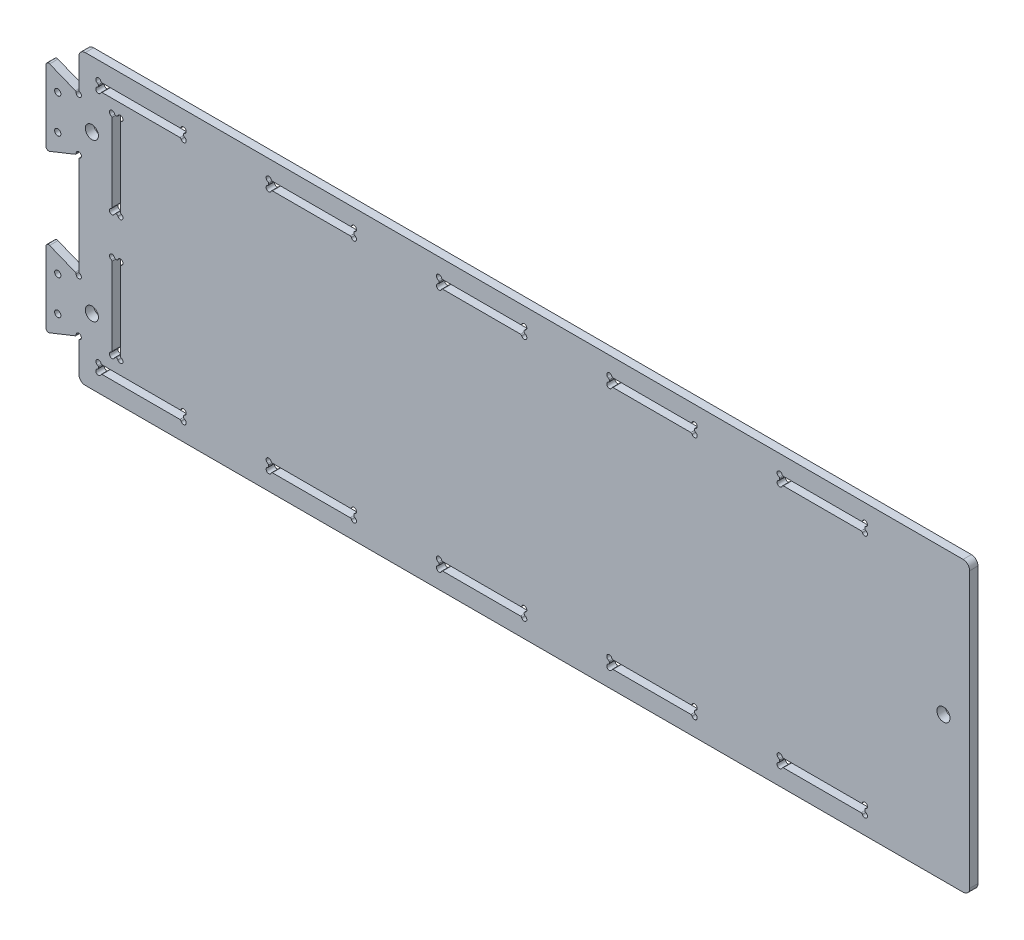
from build123d import *

# Parameters (mm, degrees)
SKETCH1_W            = 680
SKETCH1_H            = 220
BOSS_EXTRUDE1_DEPTH  = 3.175
SKETCH2_W            = 65
SKETCH2_H            = 6.35
CUT_EXTRUDE1_DEPTH   = 7.35
SKETCH3_R            = 2
CUT_EXTRUDE2_DEPTH   = 7.35
CUT_EXTRUDE3_DEPTH   = 7.35
LPATTERN1_COUNT      = 5
LPATTERN1_PITCH      = 130
MIRROR1_COPY_1_DEPTH = 7.35
MIRROR1_COPY_2_DEPTH = 7.35
MIRROR1_COPY_3_DEPTH = 7.35
MIRROR1_COPY_4_DEPTH = 7.35
SKETCH5_W            = 6.35
SKETCH5_H            = 65
CUT_EXTRUDE4_DEPTH   = 7.35
SKETCH6_R            = 2
CUT_EXTRUDE5_DEPTH   = 7.35
FILLET1_R            = 1
BOSS_EXTRUDE2_DEPTH  = 6.35
SKETCH8_R            = 2
CUT_EXTRUDE6_DEPTH   = 7.35
SKETCH10_R           = 5
CUT_EXTRUDE9_DEPTH   = 7.35
FILLET2_R            = 1
FILLET3_R            = 2
FILLET4_R            = 5
SKETCH9_R            = 2.38
CUT_EXTRUDE8_DEPTH   = 6.35


with BuildPart() as part:
    # Sketch1 → Boss-Extrude1 (new body, symmetric)
    with BuildSketch(Plane.XY):
        with Locations((340, 110)):
            Rectangle(SKETCH1_W, SKETCH1_H)
    extrude(amount=BOSS_EXTRUDE1_DEPTH, both=True)

    # Sketch2 → Cut-Extrude1 (cut, through all)
    with BuildSketch(Plane.XY.offset(3.175)):
        with Locations((567.5, 203.175)):
            Rectangle(SKETCH2_W, SKETCH2_H)
    extrude(amount=-CUT_EXTRUDE1_DEPTH, mode=Mode.SUBTRACT)

    # Sketch3 → Cut-Extrude2 (cut, through all)
    with BuildSketch(Plane.XY.offset(3.175)):
        with Locations((535, 206.35)):
            Circle(SKETCH3_R)
        with Locations((535, 200)):
            Circle(SKETCH3_R)
        with Locations((600, 200)):
            Circle(SKETCH3_R)
        with Locations((600, 206.35)):
            Circle(SKETCH3_R)
    extrude(amount=-CUT_EXTRUDE2_DEPTH, mode=Mode.SUBTRACT)

    # Sketch4 → Cut-Extrude3 (cut, through all)
    with BuildSketch(Plane.XY.offset(3.175)):
        with BuildLine():
            Line((537.828427125, 200), (597.171572875, 200))
            ThreePointArc((597.171572875, 200), (597.748923144, 199.816496581), (598.114381917, 199.333333333))
            ThreePointArc((598.114381917, 199.333333333), (601.414213562, 198.585786438), (600.666666667, 201.885618083))
            ThreePointArc((600.666666667, 201.885618083), (600.183503419, 202.251076856), (600, 202.828427125))
            Line((600, 202.828427125), (600, 203.521572875))
            ThreePointArc((600, 203.521572875), (600.183503419, 204.098923144), (600.666666667, 204.464381917))
            ThreePointArc((600.666666667, 204.464381917), (601.414213562, 207.764213562), (598.114381917, 207.016666667))
            ThreePointArc((598.114381917, 207.016666667), (597.748923144, 206.533503419), (597.171572875, 206.35))
            Line((597.171572875, 206.35), (537.828427125, 206.35))
            ThreePointArc((537.828427125, 206.35), (537.251076856, 206.533503419), (536.885618083, 207.016666667))
            ThreePointArc((536.885618083, 207.016666667), (533.585786438, 207.764213562), (534.333333333, 204.464381917))
            ThreePointArc((534.333333333, 204.464381917), (534.816496581, 204.098923144), (535, 203.521572875))
            Line((535, 203.521572875), (535, 202.828427125))
            ThreePointArc((535, 202.828427125), (534.816496581, 202.251076856), (534.333333333, 201.885618083))
            ThreePointArc((534.333333333, 201.885618083), (533.585786438, 198.585786438), (536.885618083, 199.333333333))
            ThreePointArc((536.885618083, 199.333333333), (537.251076856, 199.816496581), (537.828427125, 200))
        make_face()
    cut_extrude3 = extrude(amount=-CUT_EXTRUDE3_DEPTH, mode=Mode.SUBTRACT)

    # LPattern1: Cut-Extrude3 ×5
    with Locations(*[(-i * LPATTERN1_PITCH, 0, 0) for i in range(1, LPATTERN1_COUNT)]):
        add(cut_extrude3, mode=Mode.SUBTRACT)

    # Mirror1: Cut-Extrude3 across plane
    add(cut_extrude3.mirror(Plane.ZX.offset(110)), mode=Mode.SUBTRACT)

    # Mirror1 copy 1 sketch → Mirror1 copy 1 (cut, through all)
    with BuildSketch(Plane(origin=(-130, 220, 3.175), x_dir=(1, 0, 0), z_dir=(0, 0, 1))):
        with BuildLine():
            Line((537.828427125, -200), (597.171572875, -200))
            ThreePointArc((597.171572875, -200), (597.748923144, -199.816496581), (598.114381917, -199.333333333))
            ThreePointArc((598.114381917, -199.333333333), (601.414213562, -198.585786438), (600.666666667, -201.885618083))
            ThreePointArc((600.666666667, -201.885618083), (600.183503419, -202.251076856), (600, -202.828427125))
            Line((600, -202.828427125), (600, -203.521572875))
            ThreePointArc((600, -203.521572875), (600.183503419, -204.098923144), (600.666666667, -204.464381917))
            ThreePointArc((600.666666667, -204.464381917), (601.414213562, -207.764213562), (598.114381917, -207.016666667))
            ThreePointArc((598.114381917, -207.016666667), (597.748923144, -206.533503419), (597.171572875, -206.35))
            Line((597.171572875, -206.35), (537.828427125, -206.35))
            ThreePointArc((537.828427125, -206.35), (537.251076856, -206.533503419), (536.885618083, -207.016666667))
            ThreePointArc((536.885618083, -207.016666667), (533.585786438, -207.764213562), (534.333333333, -204.464381917))
            ThreePointArc((534.333333333, -204.464381917), (534.816496581, -204.098923144), (535, -203.521572875))
            Line((535, -203.521572875), (535, -202.828427125))
            ThreePointArc((535, -202.828427125), (534.816496581, -202.251076856), (534.333333333, -201.885618083))
            ThreePointArc((534.333333333, -201.885618083), (533.585786438, -198.585786438), (536.885618083, -199.333333333))
            ThreePointArc((536.885618083, -199.333333333), (537.251076856, -199.816496581), (537.828427125, -200))
        make_face()
    extrude(amount=-MIRROR1_COPY_1_DEPTH, mode=Mode.SUBTRACT)

    # Mirror1 copy 2 sketch → Mirror1 copy 2 (cut, through all)
    with BuildSketch(Plane(origin=(-260, 220, 3.175), x_dir=(1, 0, 0), z_dir=(0, 0, 1))):
        with BuildLine():
            Line((537.828427125, -200), (597.171572875, -200))
            ThreePointArc((597.171572875, -200), (597.748923144, -199.816496581), (598.114381917, -199.333333333))
            ThreePointArc((598.114381917, -199.333333333), (601.414213562, -198.585786438), (600.666666667, -201.885618083))
            ThreePointArc((600.666666667, -201.885618083), (600.183503419, -202.251076856), (600, -202.828427125))
            Line((600, -202.828427125), (600, -203.521572875))
            ThreePointArc((600, -203.521572875), (600.183503419, -204.098923144), (600.666666667, -204.464381917))
            ThreePointArc((600.666666667, -204.464381917), (601.414213562, -207.764213562), (598.114381917, -207.016666667))
            ThreePointArc((598.114381917, -207.016666667), (597.748923144, -206.533503419), (597.171572875, -206.35))
            Line((597.171572875, -206.35), (537.828427125, -206.35))
            ThreePointArc((537.828427125, -206.35), (537.251076856, -206.533503419), (536.885618083, -207.016666667))
            ThreePointArc((536.885618083, -207.016666667), (533.585786438, -207.764213562), (534.333333333, -204.464381917))
            ThreePointArc((534.333333333, -204.464381917), (534.816496581, -204.098923144), (535, -203.521572875))
            Line((535, -203.521572875), (535, -202.828427125))
            ThreePointArc((535, -202.828427125), (534.816496581, -202.251076856), (534.333333333, -201.885618083))
            ThreePointArc((534.333333333, -201.885618083), (533.585786438, -198.585786438), (536.885618083, -199.333333333))
            ThreePointArc((536.885618083, -199.333333333), (537.251076856, -199.816496581), (537.828427125, -200))
        make_face()
    extrude(amount=-MIRROR1_COPY_2_DEPTH, mode=Mode.SUBTRACT)

    # Mirror1 copy 3 sketch → Mirror1 copy 3 (cut, through all)
    with BuildSketch(Plane(origin=(-390, 220, 3.175), x_dir=(1, 0, 0), z_dir=(0, 0, 1))):
        with BuildLine():
            Line((537.828427125, -200), (597.171572875, -200))
            ThreePointArc((597.171572875, -200), (597.748923144, -199.816496581), (598.114381917, -199.333333333))
            ThreePointArc((598.114381917, -199.333333333), (601.414213562, -198.585786438), (600.666666667, -201.885618083))
            ThreePointArc((600.666666667, -201.885618083), (600.183503419, -202.251076856), (600, -202.828427125))
            Line((600, -202.828427125), (600, -203.521572875))
            ThreePointArc((600, -203.521572875), (600.183503419, -204.098923144), (600.666666667, -204.464381917))
            ThreePointArc((600.666666667, -204.464381917), (601.414213562, -207.764213562), (598.114381917, -207.016666667))
            ThreePointArc((598.114381917, -207.016666667), (597.748923144, -206.533503419), (597.171572875, -206.35))
            Line((597.171572875, -206.35), (537.828427125, -206.35))
            ThreePointArc((537.828427125, -206.35), (537.251076856, -206.533503419), (536.885618083, -207.016666667))
            ThreePointArc((536.885618083, -207.016666667), (533.585786438, -207.764213562), (534.333333333, -204.464381917))
            ThreePointArc((534.333333333, -204.464381917), (534.816496581, -204.098923144), (535, -203.521572875))
            Line((535, -203.521572875), (535, -202.828427125))
            ThreePointArc((535, -202.828427125), (534.816496581, -202.251076856), (534.333333333, -201.885618083))
            ThreePointArc((534.333333333, -201.885618083), (533.585786438, -198.585786438), (536.885618083, -199.333333333))
            ThreePointArc((536.885618083, -199.333333333), (537.251076856, -199.816496581), (537.828427125, -200))
        make_face()
    extrude(amount=-MIRROR1_COPY_3_DEPTH, mode=Mode.SUBTRACT)

    # Mirror1 copy 4 sketch → Mirror1 copy 4 (cut, through all)
    with BuildSketch(Plane(origin=(-520, 220, 3.175), x_dir=(1, 0, 0), z_dir=(0, 0, 1))):
        with BuildLine():
            Line((537.828427125, -200), (597.171572875, -200))
            ThreePointArc((597.171572875, -200), (597.748923144, -199.816496581), (598.114381917, -199.333333333))
            ThreePointArc((598.114381917, -199.333333333), (601.414213562, -198.585786438), (600.666666667, -201.885618083))
            ThreePointArc((600.666666667, -201.885618083), (600.183503419, -202.251076856), (600, -202.828427125))
            Line((600, -202.828427125), (600, -203.521572875))
            ThreePointArc((600, -203.521572875), (600.183503419, -204.098923144), (600.666666667, -204.464381917))
            ThreePointArc((600.666666667, -204.464381917), (601.414213562, -207.764213562), (598.114381917, -207.016666667))
            ThreePointArc((598.114381917, -207.016666667), (597.748923144, -206.533503419), (597.171572875, -206.35))
            Line((597.171572875, -206.35), (537.828427125, -206.35))
            ThreePointArc((537.828427125, -206.35), (537.251076856, -206.533503419), (536.885618083, -207.016666667))
            ThreePointArc((536.885618083, -207.016666667), (533.585786438, -207.764213562), (534.333333333, -204.464381917))
            ThreePointArc((534.333333333, -204.464381917), (534.816496581, -204.098923144), (535, -203.521572875))
            Line((535, -203.521572875), (535, -202.828427125))
            ThreePointArc((535, -202.828427125), (534.816496581, -202.251076856), (534.333333333, -201.885618083))
            ThreePointArc((534.333333333, -201.885618083), (533.585786438, -198.585786438), (536.885618083, -199.333333333))
            ThreePointArc((536.885618083, -199.333333333), (537.251076856, -199.816496581), (537.828427125, -200))
        make_face()
    extrude(amount=-MIRROR1_COPY_4_DEPTH, mode=Mode.SUBTRACT)

    # Sketch5 → Cut-Extrude4 (cut, through all)
    with BuildSketch(Plane.XY.offset(3.175)):
        with Locations((28.588269807, 62.5)):
            Rectangle(SKETCH5_W, SKETCH5_H)
        with Locations((28.588269807, 157.5)):
            Rectangle(SKETCH5_W, SKETCH5_H)
    extrude(amount=-CUT_EXTRUDE4_DEPTH, mode=Mode.SUBTRACT)

    # Sketch6 → Cut-Extrude5 (cut, through all)
    with BuildSketch(Plane.XY.offset(3.175)):
        with Locations((25.413269807, 190)):
            Circle(SKETCH6_R)
        with Locations((31.763269807, 190)):
            Circle(SKETCH6_R)
        with Locations((31.763269807, 125)):
            Circle(SKETCH6_R)
        with Locations((25.413269807, 125)):
            Circle(SKETCH6_R)
        with Locations((25.413269807, 95)):
            Circle(SKETCH6_R)
        with Locations((31.763269807, 95)):
            Circle(SKETCH6_R)
        with Locations((25.413269807, 30)):
            Circle(SKETCH6_R)
        with Locations((31.763269807, 30)):
            Circle(SKETCH6_R)
    extrude(amount=-CUT_EXTRUDE5_DEPTH, mode=Mode.SUBTRACT)

    # Fillet1
    fillet1_edges = [part.edges().sort_by_distance(p)[0] for p in [
        (27.413269807, 30, 0),
        (29.763269807, 30, 0),
        (31.763269807, 93, 0),
        (27.413269807, 95, 0),
        (27.413269807, 125, 0),
        (29.763269807, 125, 0),
        (31.763269807, 188, 0),
        (27.413269807, 190, 0),
        (29.763269807, 190, 0),
        (31.763269807, 127, 0),
        (25.413269807, 127, 0),
        (25.413269807, 93, 0),
        (31.763269807, 32, 0),
        (25.413269807, 32, 0),
        (29.763269807, 95, 0),
        (25.413269807, 188, 0),
    ]]
    fillet(fillet1_edges, radius=FILLET1_R)

    # Sketch7 → Boss-Extrude2 (add)
    with BuildSketch(Plane.XY.offset(3.175)):
        Polygon((0, 190), (-25, 200), (-25, 140), (0, 150), align=None)
        Polygon((0, 70), (-25, 80), (-25, 20), (0, 30), align=None)
    extrude(amount=-BOSS_EXTRUDE2_DEPTH)

    # Sketch8 → Cut-Extrude6 (cut, through all)
    with BuildSketch(Plane.XY.offset(3.175)):
        with Locations((0, 190)):
            Circle(SKETCH8_R)
        with Locations((0, 150)):
            Circle(SKETCH8_R)
        with Locations((0, 70)):
            Circle(SKETCH8_R)
        with Locations((0, 30)):
            Circle(SKETCH8_R)
    extrude(amount=-CUT_EXTRUDE6_DEPTH, mode=Mode.SUBTRACT)

    # Sketch10 → Cut-Extrude9 (cut, through all)
    with BuildSketch(Plane(origin=(0, 0, -3.175), x_dir=(-1, 0, 0), z_dir=(0, 0, -1))):
        with Locations((-10, 170)):
            Circle(SKETCH10_R)
        with Locations((-10, 50)):
            Circle(SKETCH10_R)
        with Locations((-660, 110)):
            Circle(SKETCH10_R)
    extrude(amount=-CUT_EXTRUDE9_DEPTH, mode=Mode.SUBTRACT)

    # Fillet2
    fillet2_edges = [part.edges().sort_by_distance(p)[0] for p in [
        (-1.856953382, 29.257218647, 0),
        (-1.856953382, 70.742781353, 0),
        (-1.856953382, 149.257218647, 0),
        (-1.856953382, 190.742781353, 0),
        (0, 192, 0),
        (0, 148, 0),
        (0, 72, 0),
        (0, 28, 0),
    ]]
    fillet(fillet2_edges, radius=FILLET2_R)

    # Fillet3
    fillet3_edges = [part.edges().sort_by_distance(p)[0] for p in [
        (-25, 200, 0),
        (-25, 140, 0),
        (-25, 80, 0),
        (-25, 20, 0),
    ]]
    fillet(fillet3_edges, radius=FILLET3_R)

    # Fillet4
    fillet4_edges = [part.edges().sort_by_distance(p)[0] for p in [
        (0, 220, 0),
        (680, 220, 0),
        (680, 0, 0),
        (0, 0, 0),
    ]]
    fillet(fillet4_edges, radius=FILLET4_R)

    # Sketch9 → Cut-Extrude8 (cut)
    with BuildSketch(Plane(origin=(0, 0, -3.175), x_dir=(-1, 0, 0), z_dir=(0, 0, -1))):
        with Locations((16.049051175, 36.790189765)):
            Circle(SKETCH9_R)
        with Locations((16.049051175, 63.209810235)):
            Circle(SKETCH9_R)
    cut_extrude8 = extrude(amount=-CUT_EXTRUDE8_DEPTH, mode=Mode.SUBTRACT)

    # Mirror2: Cut-Extrude8 across plane
    add(cut_extrude8.mirror(Plane(origin=(0, 110, 0), x_dir=(0, 0, 1), z_dir=(0, -1, 0))), mode=Mode.SUBTRACT)


solid = part.part
